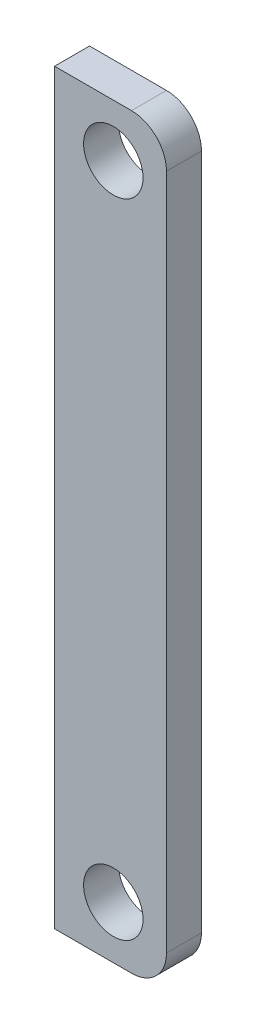
from build123d import *

# Parameters (mm, degrees)
SKETCH1_R           = 1.7
BOSS_EXTRUDE1_DEPTH = 1


with BuildPart() as part:
    # Sketch1 → Boss-Extrude1 (new body, symmetric)
    with BuildSketch(Plane.XY):
        with BuildLine():
            Line((35.2, 21.36), (30.8, 21.36))
            Line((30.8, 21.36), (30.8, -21.36))
            Line((30.8, -21.36), (35.2, -21.36))
            ThreePointArc((35.2, -21.36), (36.614213562, -20.774213562), (37.2, -19.36))
            Line((37.2, -19.36), (37.2, 19.36))
            ThreePointArc((37.2, 19.36), (36.614213562, 20.774213562), (35.2, 21.36))
        make_face()
        with Locations((34.16, -18.36)):
            Circle(SKETCH1_R, mode=Mode.SUBTRACT)
        with Locations((34.16, 18.36)):
            Circle(SKETCH1_R, mode=Mode.SUBTRACT)
    extrude(amount=BOSS_EXTRUDE1_DEPTH, both=True)


solid = part.part
